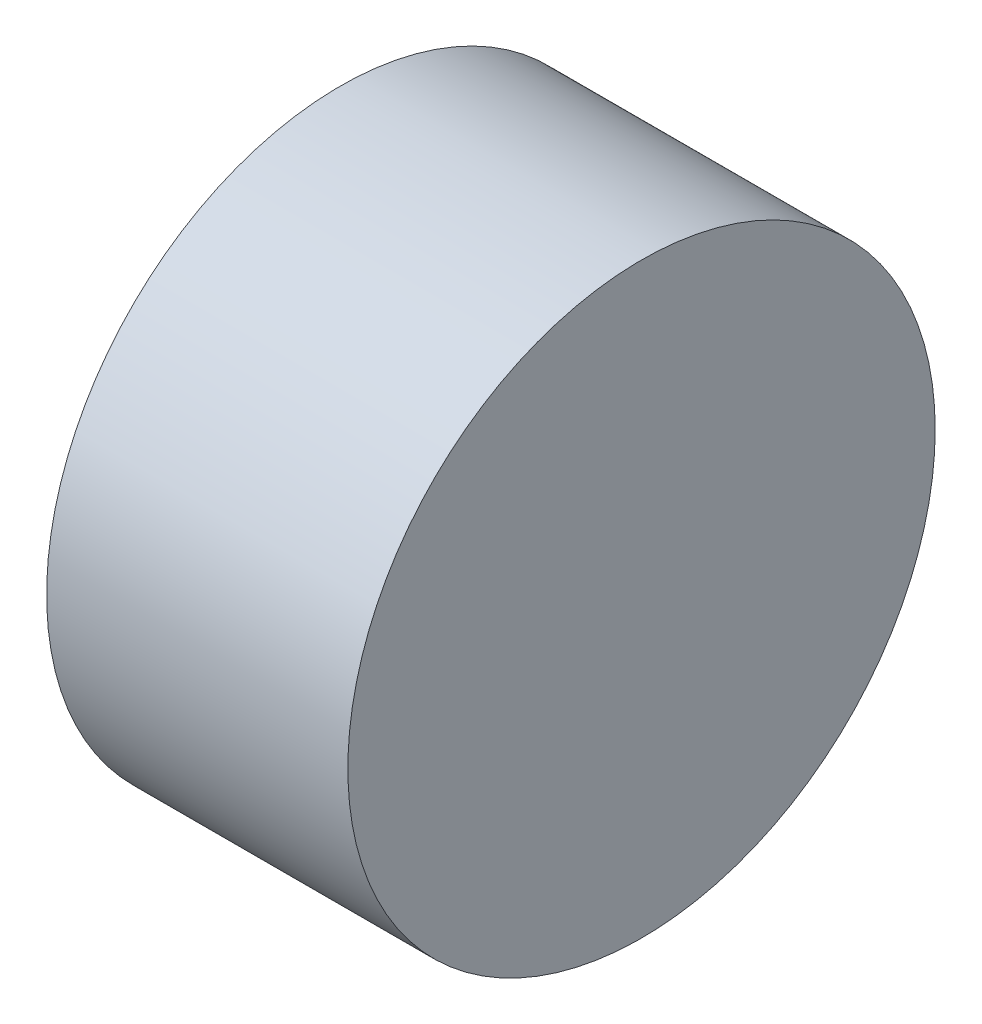
from build123d import *

# Parameters (mm, degrees)
SKETCH_1_R          = 7.8
EXTRUDE_1_DEPTH     = 8
SKETCH_2_R          = 1.5
CUT_EXTRUDE_1_DEPTH = 1


with BuildPart() as part:
    # Эскиз1 → Бобышка-Вытянуть1 (new body)
    with BuildSketch(Plane(origin=(0, 0, 0), x_dir=(0, 0, -1), z_dir=(1, 0, 0))):
        Circle(SKETCH_1_R)
    extrude(amount=EXTRUDE_1_DEPTH)

    # Эскиз2 → Вырез-Вытянуть1 (cut)
    with BuildSketch(Plane.ZY):
        Circle(SKETCH_2_R)
    extrude(amount=-CUT_EXTRUDE_1_DEPTH, mode=Mode.SUBTRACT)


solid = part.part
